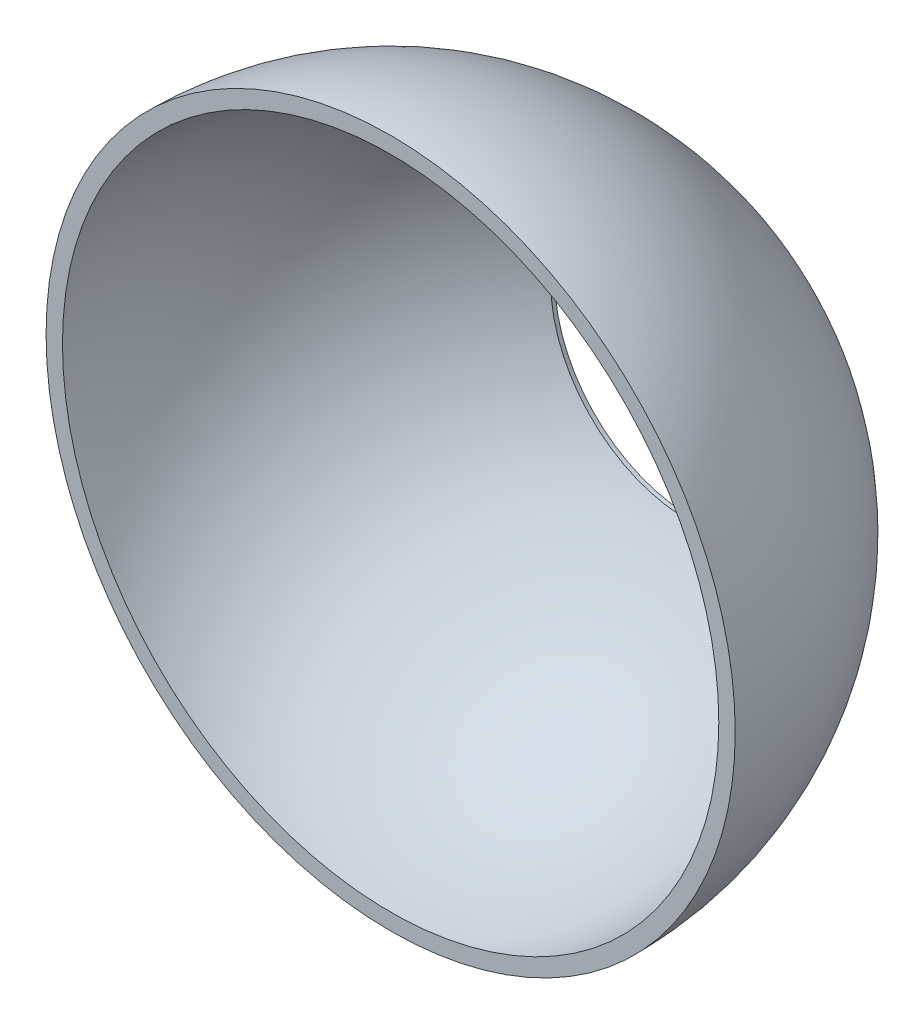
from build123d import *


with BuildPart() as part:
    # Sketch2 → Main Body (revolve)
    with BuildSketch(Plane(origin=(0, 0, 0), x_dir=(1, 0, 0), z_dir=(0, 1, 0))):
        with BuildLine():
            Line((10, 0), (10.5, 0))
            ThreePointArc((10.5, 0), (9.038435703, 5.343845062), (5.060632372, 9.2))
            Line((5.060632372, 9.2), (4.2, 9.2))
            Line((4.2, 9.2), (4.2, 9.075241044))
            ThreePointArc((4.2, 9.075241044), (8.426149773, 5.385164807), (10, 0))
        make_face()
    revolve(axis=Axis((0, 0, 0), (0, 0, -1)))


solid = part.part
